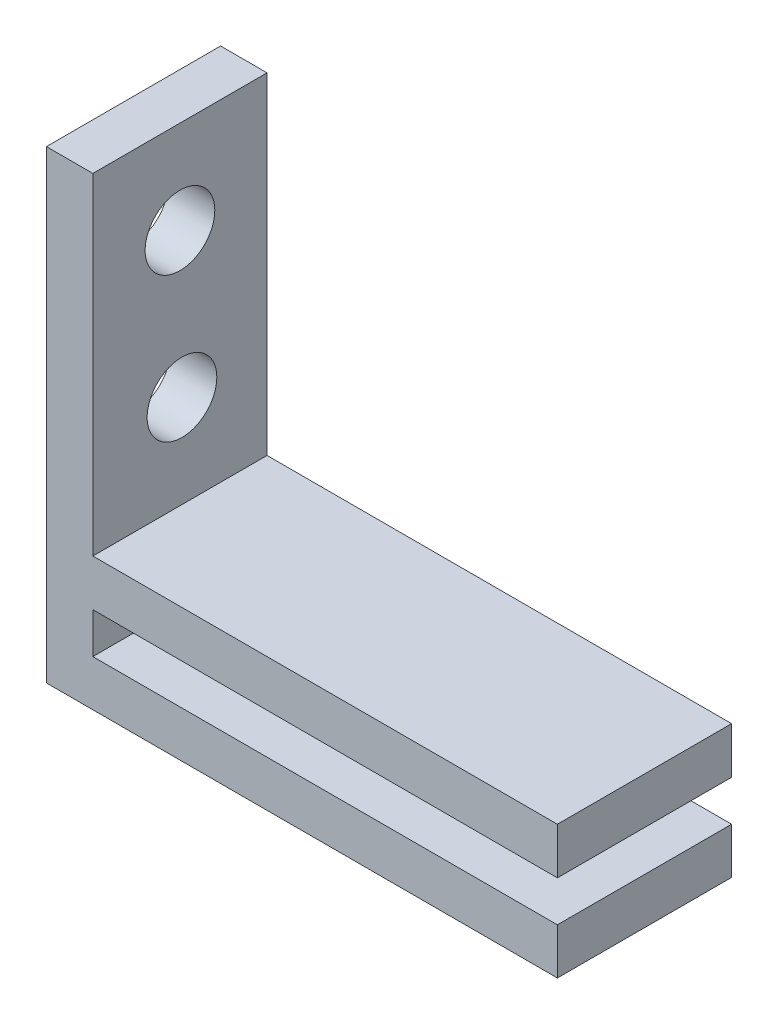
from build123d import *

# Parameters (mm, degrees)
SKETCH1_W           = 7.5
SKETCH1_H           = 20
BOSS_EXTRUDE2_DEPTH = 2
SKETCH2_W           = 7.5
SKETCH2_H           = 1.98347932
BOSS_EXTRUDE3_DEPTH = 20
SKETCH3_W           = 7.5
SKETCH3_H           = 2
BOSS_EXTRUDE4_DEPTH = 20
SKETCH5_R           = 1.5
CUT_EXTRUDE1_DEPTH  = 20


with BuildPart() as part:
    # Sketch1 → Boss-Extrude2 (new body)
    with BuildSketch(Plane(origin=(0, 0, 0), x_dir=(0, 0, -1), z_dir=(1, 0, 0))):
        with Locations((3.009581882, -0.975609756)):
            Rectangle(SKETCH1_W, SKETCH1_H)
    extrude(amount=BOSS_EXTRUDE2_DEPTH)

    # Sketch2 → Boss-Extrude3 (add)
    with BuildSketch(Plane(origin=(2, 0, 0), x_dir=(0, 0, -1), z_dir=(1, 0, 0))):
        with Locations((3.009581882, -9.983870096)):
            Rectangle(SKETCH2_W, SKETCH2_H)
    extrude(amount=BOSS_EXTRUDE3_DEPTH)

    # Sketch3 → Boss-Extrude4 (add)
    with BuildSketch(Plane(origin=(2, 0, 0), x_dir=(0, 0, -1), z_dir=(1, 0, 0))):
        with Locations((3.009581882, -6.242130436)):
            Rectangle(SKETCH3_W, SKETCH3_H)
    extrude(amount=BOSS_EXTRUDE4_DEPTH)

    # Sketch5 → Cut-Extrude1 (cut)
    with BuildSketch(Plane(origin=(2, 0, 0), x_dir=(0, 0, -1), z_dir=(1, 0, 0))):
        with Locations((3.009581882, 5.024390244)):
            Circle(SKETCH5_R)
        with Locations((3.096458319, -1.242130436)):
            Circle(SKETCH5_R)
    extrude(amount=-CUT_EXTRUDE1_DEPTH, mode=Mode.SUBTRACT)


solid = part.part
